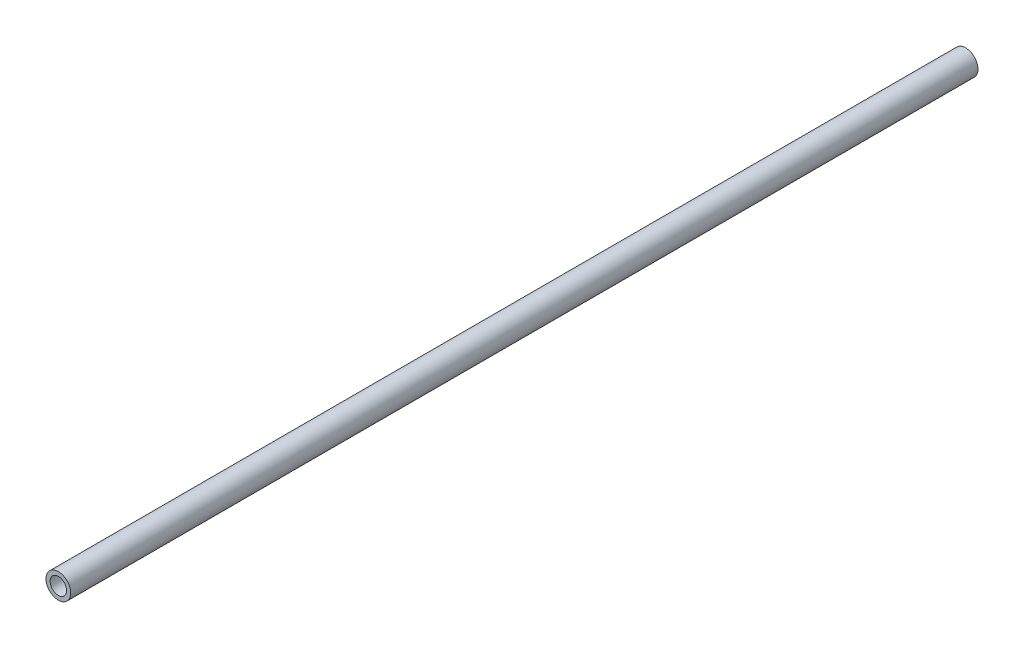
from build123d import *

# Parameters (mm, degrees)
SKETCH1_R           = 7.62
SKETCH1_R_2         = 5.08
BOSS_EXTRUDE1_DEPTH = 558.8


with BuildPart() as part:
    # Sketch1 → Boss-Extrude1 (new body)
    with BuildSketch(Plane.XY):
        Circle(SKETCH1_R)
        Circle(SKETCH1_R_2, mode=Mode.SUBTRACT)
    extrude(amount=BOSS_EXTRUDE1_DEPTH)


solid = part.part
